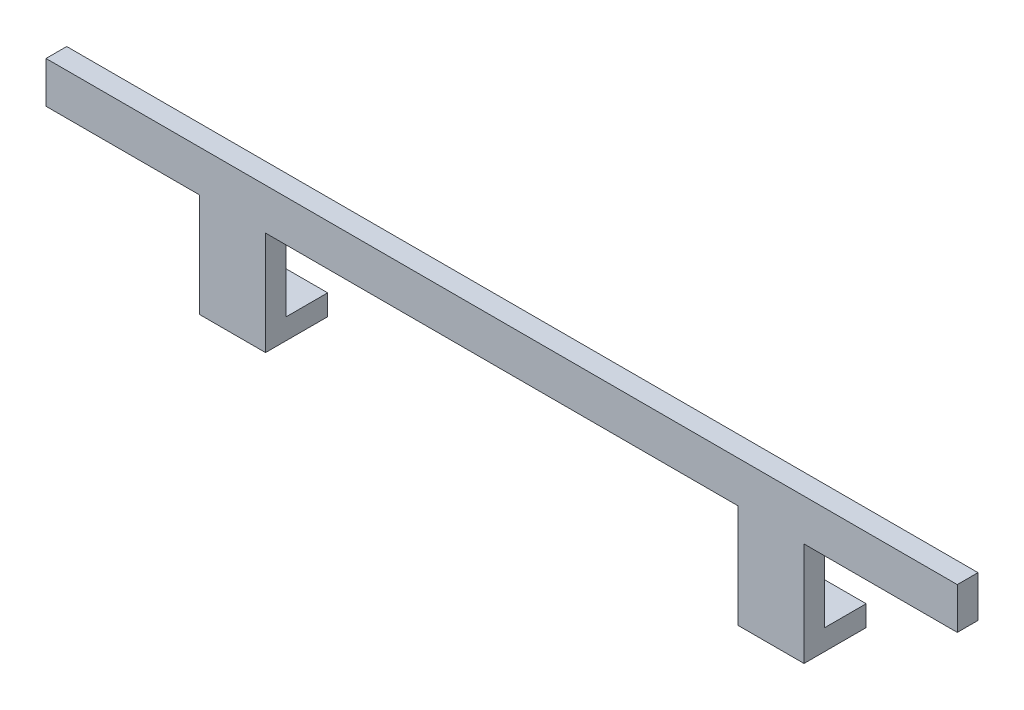
from build123d import *

# Parameters (mm, degrees)
SALIENTE_EXTRUIR1_DEPTH = 5
CROQUIS2_W              = 16
CROQUIS2_H              = 5
SALIENTE_EXTRUIR2_DEPTH = 10
CORTAR_EXTRUIR1_REACH   = 7
CROQUIS3_R              = 2


with BuildPart() as part:
    # Croquis1 → Saliente-Extruir1 (new body)
    with BuildSketch(Plane.XY):
        Polygon((-110, 25), (-73, 25), (-73, 0), (-57, 0), (-57, 25), (57, 25), (57, 0), (73, 0), (73, 25), (110, 25), (110, 35), (-110, 35), align=None)
    extrude(amount=SALIENTE_EXTRUIR1_DEPTH)

    # Croquis2 → Saliente-Extruir2 (add)
    with BuildSketch(Plane(origin=(0, 0, 0), x_dir=(-1, 0, 0), z_dir=(0, 0, -1))):
        with Locations((65, 2.5)):
            Rectangle(CROQUIS2_W, CROQUIS2_H)
        with Locations((-65, 2.5)):
            Rectangle(CROQUIS2_W, CROQUIS2_H)
    extrude(amount=SALIENTE_EXTRUIR2_DEPTH)

    # Croquis3 → Cortar-Extruir1 (cut, up to next)
    with BuildSketch(Plane(origin=(0, 5, 0), x_dir=(1, 0, 0), z_dir=(0, 1, 0)), mode=Mode.PRIVATE) as cortar_extruir1_sk1:
        with Locations((65, 5)):
            Circle(CROQUIS3_R)
    cortar_extruir1_tool1 = extrude(cortar_extruir1_sk1.sketch, amount=-CORTAR_EXTRUIR1_REACH, mode=Mode.PRIVATE) & part.part
    add(cortar_extruir1_tool1.solids().sort_by_distance((65, 5, -5))[0], mode=Mode.SUBTRACT)
    # Croquis3 → Cortar-Extruir1 (cut, up to next)
    with BuildSketch(Plane(origin=(0, 5, 0), x_dir=(1, 0, 0), z_dir=(0, 1, 0)), mode=Mode.PRIVATE) as cortar_extruir1_sk2:
        with Locations((-65, 5)):
            Circle(CROQUIS3_R)
    cortar_extruir1_tool2 = extrude(cortar_extruir1_sk2.sketch, amount=-CORTAR_EXTRUIR1_REACH, mode=Mode.PRIVATE) & part.part
    add(cortar_extruir1_tool2.solids().sort_by_distance((-65, 5, -5))[0], mode=Mode.SUBTRACT)


solid = part.part
